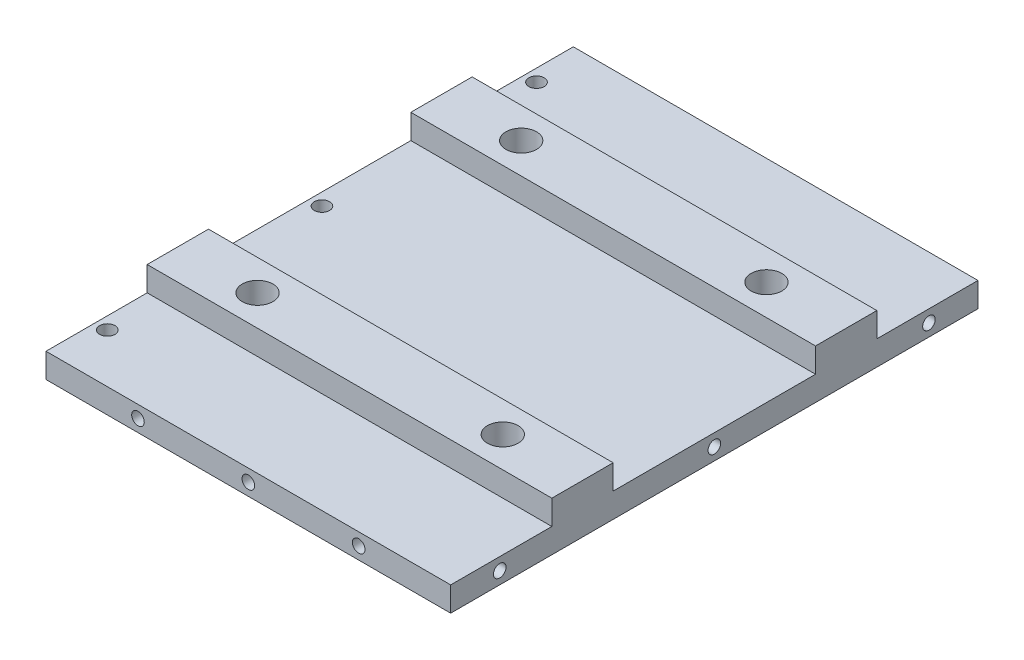
from build123d import *

# Parameters (mm, degrees)
SKETCH_1_R                    = 1.25
EXTRUDE_1_DEPTH               = 4
HOLE_WIZARD_M2_5_1_AT_2_COUNT = 2
HOLE_WIZARD_M2_5_1_AT_2_PITCH = 18
HOLE_WIZARD_M2_5_1_AT_3_COUNT = 2
HOLE_WIZARD_M2_5_1_AT_3_PITCH = 36
SKETCH_7_W                    = 66
SKETCH_7_H                    = 10
EXTRUDE_2_DEPTH               = 4
SKETCH_7_3_R                  = 2.5
CUT_EXTRUDE_1_DEPTH           = 4
HOLE_WIZARD_M2_5_2_D          = 2.05
HOLE_WIZARD_M2_5_2_DEPTH      = 7.25
HOLE_WIZARD_M2_5_2_TIP        = 0.615882135


with BuildPart() as part:
    # 草图1 → 凸台-拉伸1 (new body)
    with BuildSketch(Plane(origin=(0, 0, 0), x_dir=(1, 0, 0), z_dir=(0, 1, 0))):
        Polygon((0, 0), (0, 43), (66, 43), (66, -43), (0, -43), align=None)
        with Locations((2, 0)):
            Circle(SKETCH_1_R, mode=Mode.SUBTRACT)
        with Locations((2, 35)):
            Circle(SKETCH_1_R, mode=Mode.SUBTRACT)
        with Locations((2, -35)):
            Circle(SKETCH_1_R, mode=Mode.SUBTRACT)
    extrude(amount=EXTRUDE_1_DEPTH)

    # 草图6 → M2.5 螺纹孔1 (revolve, cut)
    with BuildSketch(Plane(origin=(15, 2, 43), x_dir=(0, -1, 0), z_dir=(1, 0, 0))):
        Polygon((0, 0), (0, 8.865882135), (1.025, 8.25), (1.025, 0), align=None)
    hole_wizard_m2_5_1 = revolve(axis=Axis((15, 2, 49.35), (0, 0, -1)), mode=Mode.SUBTRACT)

    # M2.5 螺纹孔1 at 2: M2.5 螺纹孔1 ×2
    with Locations(*[(i * HOLE_WIZARD_M2_5_1_AT_2_PITCH, 0, 0) for i in range(1, HOLE_WIZARD_M2_5_1_AT_2_COUNT)]):
        add(hole_wizard_m2_5_1, mode=Mode.SUBTRACT)

    # M2.5 螺纹孔1 at 3: M2.5 螺纹孔1 ×2
    with Locations(*[(i * HOLE_WIZARD_M2_5_1_AT_3_PITCH, 0, 0) for i in range(1, HOLE_WIZARD_M2_5_1_AT_3_COUNT)]):
        add(hole_wizard_m2_5_1, mode=Mode.SUBTRACT)

    # 镜向1: M2.5 螺纹孔1 across plane
    add(hole_wizard_m2_5_1.mirror(Plane.XY), mode=Mode.SUBTRACT)

    # 镜向1 copy 1 sketch → 镜向1 copy 1 (revolve, cut)
    with BuildSketch(Plane(origin=(33, 2, -43), x_dir=(0, -1, 0), z_dir=(1, 0, 0))):
        Polygon((0, 0), (0, -8.865882135), (1.025, -8.25), (1.025, 0), align=None)
    revolve(axis=Axis((33, 2, -49.35), (0, 0, -1)), mode=Mode.SUBTRACT)

    # 镜向1 copy 2 sketch → 镜向1 copy 2 (revolve, cut)
    with BuildSketch(Plane(origin=(51, 2, -43), x_dir=(0, -1, 0), z_dir=(1, 0, 0))):
        Polygon((0, 0), (0, -8.865882135), (1.025, -8.25), (1.025, 0), align=None)
    revolve(axis=Axis((51, 2, -49.35), (0, 0, -1)), mode=Mode.SUBTRACT)

    # 草图7 → 凸台-拉伸2 (add)
    with BuildSketch(Plane(origin=(0, 4, 0), x_dir=(1, 0, 0), z_dir=(0, 1, 0))):
        with Locations((33, 21.5)):
            Rectangle(SKETCH_7_W, SKETCH_7_H)
        with Locations((33, -21.5)):
            Rectangle(SKETCH_7_W, SKETCH_7_H)
    extrude(amount=EXTRUDE_2_DEPTH)

    # 草图7<3> → 切除-拉伸1 (cut, symmetric)
    with BuildSketch(Plane(origin=(0, 4, 0), x_dir=(1, 0, 0), z_dir=(0, 1, 0))):
        with Locations((13, 21.5)):
            Circle(SKETCH_7_3_R)
        with Locations((53, 21.5)):
            Circle(SKETCH_7_3_R)
        with Locations((53, -21.5)):
            Circle(SKETCH_7_3_R)
        with Locations((13, -21.5)):
            Circle(SKETCH_7_3_R)
    extrude(amount=CUT_EXTRUDE_1_DEPTH, both=True, mode=Mode.SUBTRACT)

    # M2.5 螺纹孔2
    with Locations(Plane(origin=(66, 0, 0), x_dir=(0, 0, -1), z_dir=(1, 0, 0))):
        with Locations((-35, 2), (0, 2), (35, 2)):
            Hole(HOLE_WIZARD_M2_5_2_D / 2, depth=HOLE_WIZARD_M2_5_2_DEPTH)
            with Locations((0, 0, -(HOLE_WIZARD_M2_5_2_DEPTH + HOLE_WIZARD_M2_5_2_TIP / 2))):  # 118° drill point
                Cone(0, HOLE_WIZARD_M2_5_2_D / 2, HOLE_WIZARD_M2_5_2_TIP, mode=Mode.SUBTRACT)


solid = part.part
